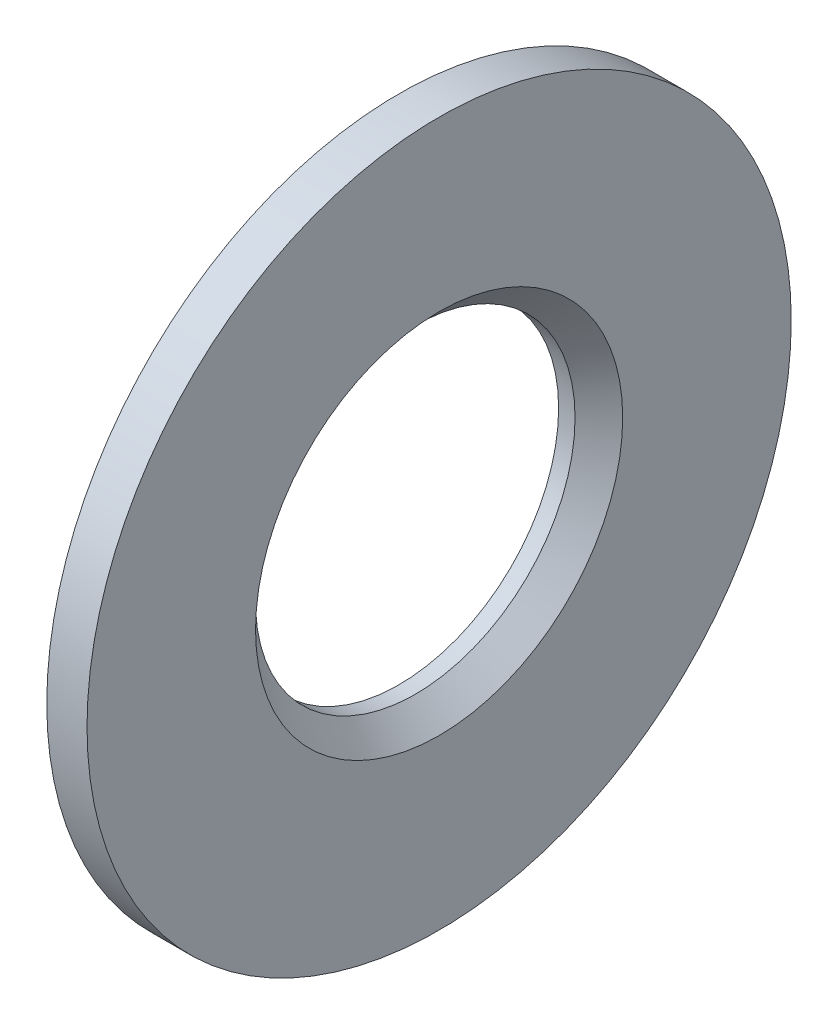
from build123d import *

# Parameters (mm, degrees)
SKETCH1_R           = 11.1125
BOSS_EXTRUDE1_DEPTH = 1.27


with BuildPart() as part:
    # Sketch1 → Boss-Extrude1 (new body)
    with BuildSketch(Plane(origin=(0, 0, 0), x_dir=(0, 0, -1), z_dir=(1, 0, 0))):
        Circle(SKETCH1_R)
    extrude(amount=BOSS_EXTRUDE1_DEPTH)

    # Sketch2 → 3/8 Clearance Hole1 (revolve, cut)
    with BuildSketch(Plane(origin=(1.27, 0, 0), x_dir=(0, 0, -1), z_dir=(0, 1, 0))):
        Polygon((0, 0), (0, 1.27), (5.0419, 1.27), (5.0419, 0.75184), (5.79374, 0), align=None)
    revolve(axis=Axis((7.62, 0, 0), (-1, 0, 0)), mode=Mode.SUBTRACT)


solid = part.part
